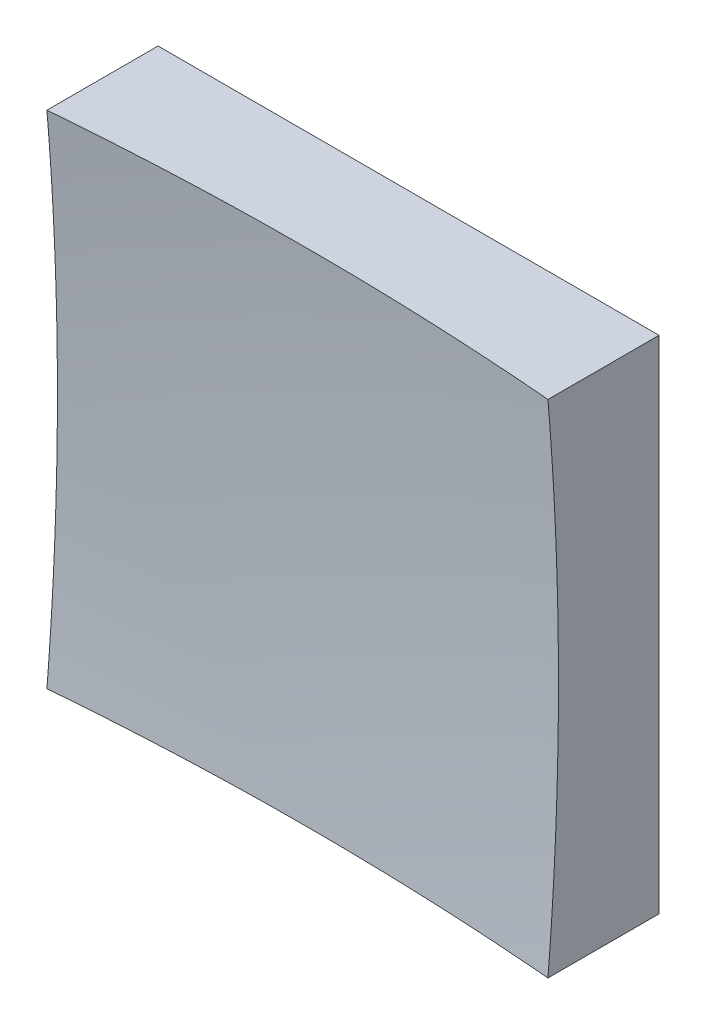
from build123d import *

# Parameters (mm, degrees)
SKETCH_1_W      = 50
SKETCH_1_H      = 50
EXTRUDE_1_DEPTH = 50


with BuildPart() as part:
    # 草图1 → 凸台-拉伸1 (new body)
    with BuildSketch(Plane.XY):
        Rectangle(SKETCH_1_W, SKETCH_1_H)
    extrude(amount=EXTRUDE_1_DEPTH)

    # 草图2 → 切除-旋转2 (revolve, cut)
    with BuildSketch(Plane(origin=(0, 0, 0), x_dir=(1, 0, 0), z_dir=(0, 1, 0))):
        with BuildLine():
            Line((292.453638544, -242.13544061), (0, -242.13544061))
            Line((0, -242.13544061), (0, -9))
            ThreePointArc((0, -9), (187.003518928, -74.41593424), (292.453638544, -242.13544061))
        make_face()
    revolve(axis=Axis((0, 0, 242.13544061), (0, 0, -1)), mode=Mode.SUBTRACT)


solid = part.part
